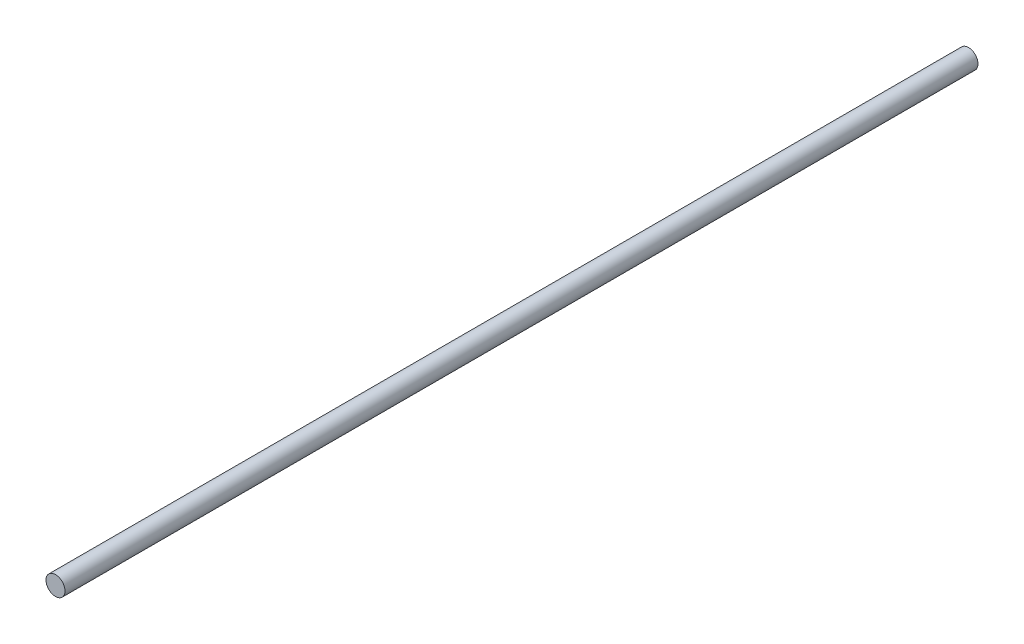
from build123d import *

# Parameters (mm, degrees)
SKETCH1_R           = 1.5875
BOSS_EXTRUDE1_DEPTH = 152.4


with BuildPart() as part:
    # Sketch1 → Boss-Extrude1 (new body)
    with BuildSketch(Plane.XY):
        Circle(SKETCH1_R)
    extrude(amount=BOSS_EXTRUDE1_DEPTH)


solid = part.part
